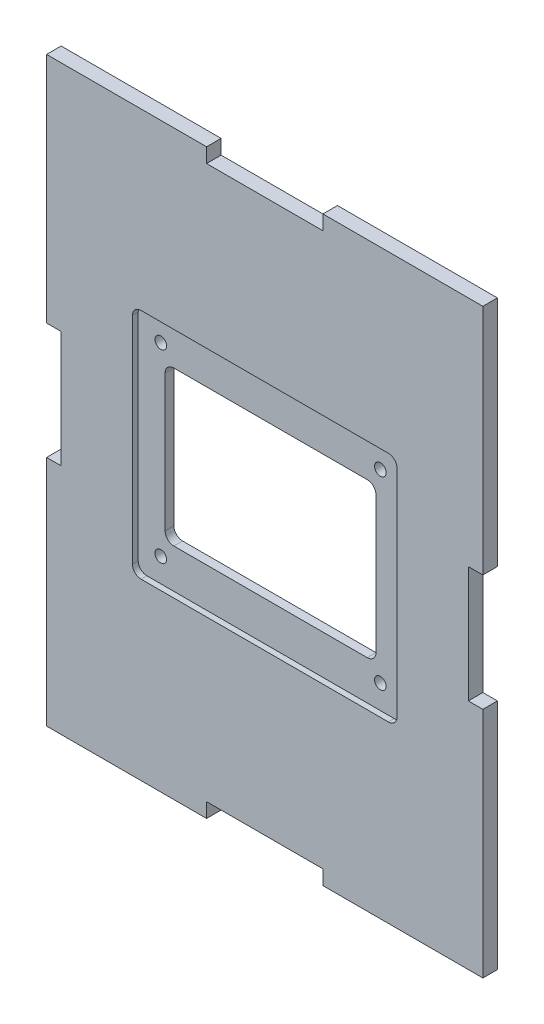
from build123d import *

# Parameters (mm, degrees)
CROQUIS1_W              = 150
CROQUIS1_H              = 200
SALIENTE_EXTRUIR1_DEPTH = 5
CROQUIS3_R              = 2
CROQUIS3_W              = 40
CROQUIS3_H              = 5
CROQUIS3_W_2            = 5
CROQUIS3_H_2            = 40
CROQUIS3_W_3            = 72.5
CROQUIS3_H_3            = 53
CORTAR_EXTRUIR2_DEPTH   = 5
CROQUIS4_W              = 91
CROQUIS4_H              = 80
CORTAR_EXTRUIR3_DEPTH   = 2
REDONDEO1_R             = 3


with BuildPart() as part:
    # Croquis1 → Saliente-Extruir1 (new body)
    with BuildSketch(Plane.XY):
        Rectangle(CROQUIS1_W, CROQUIS1_H)
    extrude(amount=SALIENTE_EXTRUIR1_DEPTH)

    # Croquis3 → Cortar-Extruir2 (cut)
    with BuildSketch(Plane.XY.offset(5)):
        with Locations((-37.75, 31.8)):
            Circle(CROQUIS3_R)
        with Locations((37.75, 31.8)):
            Circle(CROQUIS3_R)
        with Locations((37.75, -31.8)):
            Circle(CROQUIS3_R)
        with Locations((-37.75, -31.8)):
            Circle(CROQUIS3_R)
        with Locations((0, 97.5)):
            Rectangle(CROQUIS3_W, CROQUIS3_H)
        with Locations((0, -97.5)):
            Rectangle(CROQUIS3_W, CROQUIS3_H)
        with Locations((-72.5, 0)):
            Rectangle(CROQUIS3_W_2, CROQUIS3_H_2)
        with Locations((72.5, 0)):
            Rectangle(CROQUIS3_W_2, CROQUIS3_H_2)
        Rectangle(CROQUIS3_W_3, CROQUIS3_H_3)
    extrude(amount=-CORTAR_EXTRUIR2_DEPTH, mode=Mode.SUBTRACT)

    # Croquis4 → Cortar-Extruir3 (cut)
    with BuildSketch(Plane.XY.offset(5)):
        Rectangle(CROQUIS4_W, CROQUIS4_H)
    extrude(amount=-CORTAR_EXTRUIR3_DEPTH, mode=Mode.SUBTRACT)

    # Redondeo1
    redondeo1_edges = [part.edges().sort_by_distance(p)[0] for p in [
        (-45.5, -40, 4),
        (-45.5, 40, 4),
        (45.5, 40, 4),
        (45.5, -40, 4),
        (36.25, 26.5, 1.5),
        (36.25, -26.5, 1.5),
        (-36.25, -26.5, 1.5),
        (-36.25, 26.5, 1.5),
    ]]
    fillet(redondeo1_edges, radius=REDONDEO1_R)


solid = part.part
